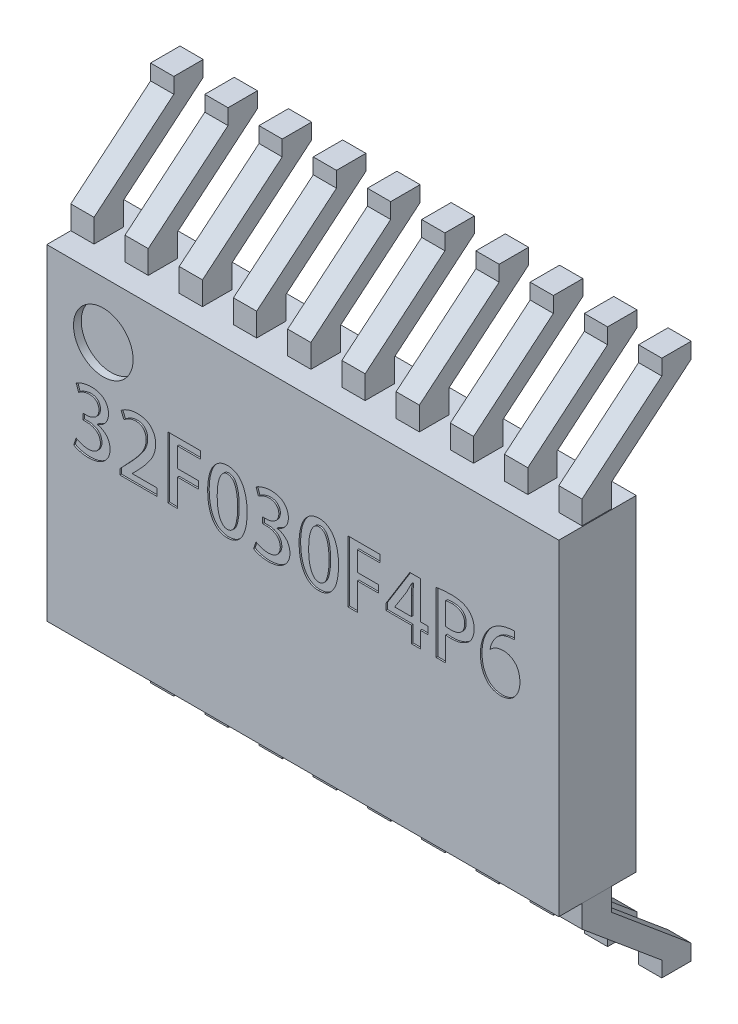
from build123d import *

# Parameters (mm, degrees)
ESQUISSE1_W                = 6.61
ESQUISSE1_H                = 4.21
CORPS_DEPTH                = 1
ESQUISSE2_R                = 0.385
ENL_V_MAT_EXTRU_1_DEPTH    = 0.1
TEXTE_DEPTH                = 0.02
BOSS_EXTRU_3_DEPTH         = 0.3
R_P_TITION_LIN_AIRE2_COUNT = 10
R_P_TITION_LIN_AIRE2_PITCH = 0.7
SYM_TRIE1_COPY_1_DEPTH     = 0.3
SYM_TRIE1_COPY_2_DEPTH     = 0.3
SYM_TRIE1_COPY_3_DEPTH     = 0.3
SYM_TRIE1_COPY_4_DEPTH     = 0.3
SYM_TRIE1_COPY_5_DEPTH     = 0.3
SYM_TRIE1_COPY_6_DEPTH     = 0.3
SYM_TRIE1_COPY_7_DEPTH     = 0.3
SYM_TRIE1_COPY_8_DEPTH     = 0.3
SYM_TRIE1_COPY_9_DEPTH     = 0.3


with BuildPart() as part:
    # Esquisse1 → Corps (new body)
    with BuildSketch(Plane.XY):
        Rectangle(ESQUISSE1_W, ESQUISSE1_H)
    extrude(amount=CORPS_DEPTH)

    # Esquisse2 → Enlèv. mat.-Extru.1 (cut)
    with BuildSketch(Plane.XY.offset(1)):
        with Locations((-2.575, 1.375)):
            Circle(ESQUISSE2_R)
    extrude(amount=-ENL_V_MAT_EXTRU_1_DEPTH, mode=Mode.SUBTRACT)

    # Esquisse3 → Texte (cut)
    with BuildSketch(Plane.XY.offset(1)):
        with BuildLine():
            add(Edge.make_bspline(
                [(-2.65303754, 0.421072717), (-2.647275821, 0.423050885), (-2.635918271, 0.426950267), (-2.619618319, 0.433860521), (-2.604408314, 0.44175305), (-2.590341582, 0.450549268), (-2.577253928, 0.460085935), (-2.565245508, 0.470492798), (-2.554535954, 0.481973881), (-2.544626724, 0.493988351), (-2.536120974, 0.506831635), (-2.528593683, 0.520098203), (-2.522293079, 0.533876611), (-2.516923774, 0.548027332), (-2.513018844, 0.56273688), (-2.510176776, 0.577844682), (-2.508265443, 0.593451553), (-2.508046918, 0.604025715), (-2.507936417, 0.60937275)],
                knots=[0, 0, 0, 0, 1.142850461, 2.252796655, 3.318527559, 4.354869455, 5.362872949, 6.354647905, 7.33116108, 8.305795594, 9.273479687, 10.217594684, 11.165254112, 12.113667972, 13.054082589, 14.016532539, 14.997020217, 16, 16, 16, 16], degree=3))
            add(Edge.make_bspline(
                [(-2.507936417, 0.60937275), (-2.508050098, 0.6160334), (-2.508273196, 0.629104953), (-2.510966223, 0.648283449), (-2.515190663, 0.666652481), (-2.521002821, 0.684247385), (-2.528861931, 0.700852669), (-2.538280244, 0.716644326), (-2.549339422, 0.731703408), (-2.562216712, 0.745727288), (-2.576706475, 0.758706), (-2.593170916, 0.7698765), (-2.611273029, 0.779450581), (-2.631121731, 0.787274025), (-2.652642483, 0.793700889), (-2.676013743, 0.798040932), (-2.70105348, 0.801187733), (-2.718357015, 0.801800391), (-2.72728642, 0.80211655)],
                knots=[0, 0, 0, 0, 0.970193423, 1.904008561, 2.816199263, 3.715045635, 4.598913464, 5.488196567, 6.391622429, 7.316994192, 8.258747533, 9.220312128, 10.209256713, 11.237617249, 12.325225682, 13.477568758, 14.698311634, 16, 16, 16, 16], degree=3))
            add(Edge.make_bspline(
                [(-2.72728642, 0.80211655), (-2.737423176, 0.801803048), (-2.757396521, 0.801185327), (-2.786723284, 0.797867905), (-2.81479364, 0.792372331), (-2.841342747, 0.78517277), (-2.865919415, 0.776659421), (-2.888035312, 0.767221444), (-2.907791824, 0.757508404), (-2.919350837, 0.749637385), (-2.924867711, 0.745880712)],
                knots=[0, 0, 0, 0, 1.168281151, 2.301967287, 3.396324189, 4.461200567, 5.469347965, 6.390373579, 7.23175906, 8, 8, 8, 8], degree=3))
            Line((-2.924867711, 0.745880712), (-2.894431877, 0.657171766))
            add(Edge.make_bspline(
                [(-2.894431877, 0.657171766), (-2.890312527, 0.660154959), (-2.881689893, 0.666399387), (-2.867258144, 0.674720571), (-2.851206862, 0.68288386), (-2.833694595, 0.690663427), (-2.815089464, 0.697746024), (-2.795384377, 0.702600431), (-2.775176939, 0.706116111), (-2.761415737, 0.706723996), (-2.754497309, 0.707029609)],
                knots=[0, 0, 0, 0, 0.808951706, 1.693300174, 2.647298677, 3.674056458, 4.742195602, 5.810003555, 6.898981895, 8, 8, 8, 8], degree=3))
            add(Edge.make_bspline(
                [(-2.754497309, 0.707029609), (-2.749452824, 0.706857939), (-2.739634004, 0.706523793), (-2.725418592, 0.704707528), (-2.712224678, 0.70183808), (-2.700075733, 0.698065024), (-2.688849206, 0.693405675), (-2.678744418, 0.687475999), (-2.669583869, 0.680608445), (-2.661400661, 0.672911816), (-2.654296993, 0.664368296), (-2.648064817, 0.655260776), (-2.642755497, 0.645605387), (-2.63853815, 0.635391552), (-2.63515538, 0.624677873), (-2.632755768, 0.613393758), (-2.6314001, 0.601545302), (-2.631228462, 0.593503137), (-2.631141277, 0.589418098)],
                knots=[0, 0, 0, 0, 1.256626411, 2.445955828, 3.563592353, 4.615523118, 5.610904047, 6.583878032, 7.525171958, 8.457385665, 9.374952795, 10.287009995, 11.202514788, 12.113880905, 13.034789483, 13.997264759, 14.982705545, 16, 16, 16, 16], degree=3))
            add(Edge.make_bspline(
                [(-2.631141277, 0.589418098), (-2.631527439, 0.583861326), (-2.632280429, 0.57302598), (-2.635355326, 0.557361818), (-2.639862522, 0.542808069), (-2.645819528, 0.529376866), (-2.653052856, 0.517001959), (-2.661961305, 0.50586206), (-2.672305611, 0.495843616), (-2.687776877, 0.484171207), (-2.708393418, 0.472154822), (-2.734338588, 0.461776114), (-2.760850793, 0.454980846), (-2.778896557, 0.454305511), (-2.787906234, 0.453968338)],
                knots=[0, 0, 0, 0, 0.870129898, 1.696696992, 2.489031529, 3.247306791, 3.989032865, 4.723528156, 5.470049698, 6.234235541, 7.748841047, 9.18391766, 10.59401934, 12, 12, 12, 12], degree=3))
            Line((-2.787906234, 0.453968338), (-2.839051398, 0.454119362))
            Line((-2.839051398, 0.454119362), (-2.839051398, 0.377928871))
            Line((-2.839051398, 0.377928871), (-2.785760749, 0.377928871))
            add(Edge.make_bspline(
                [(-2.785760749, 0.377928871), (-2.78017334, 0.377801343), (-2.769115482, 0.377548954), (-2.752746131, 0.375881796), (-2.736931418, 0.3730261), (-2.721688187, 0.369034089), (-2.706907991, 0.364112105), (-2.692756875, 0.357697772), (-2.679103028, 0.350283677), (-2.666097069, 0.341837341), (-2.653911145, 0.332347915), (-2.643516442, 0.321107807), (-2.634261145, 0.30895681), (-2.626698198, 0.295421209), (-2.620796377, 0.280611452), (-2.616475375, 0.264572043), (-2.61334401, 0.247379562), (-2.612716934, 0.235438645), (-2.612395998, 0.229327329)],
                knots=[0, 0, 0, 0, 1.046331669, 2.070760762, 3.07769869, 4.052736355, 5.019611495, 5.991172427, 6.958185709, 7.926625299, 8.893408334, 9.841308705, 10.784972102, 11.748294832, 12.73486321, 13.762806798, 14.855013103, 16, 16, 16, 16], degree=3))
            add(Edge.make_bspline(
                [(-2.612395998, 0.229327329), (-2.61245387, 0.224785863), (-2.612568099, 0.215821819), (-2.614355069, 0.202634781), (-2.616969009, 0.189777472), (-2.621200711, 0.177400279), (-2.626224107, 0.165198325), (-2.632889587, 0.153582483), (-2.640405805, 0.142182868), (-2.64917872, 0.131275389), (-2.659213388, 0.12110422), (-2.670893297, 0.112253473), (-2.683976122, 0.104726082), (-2.698440286, 0.09830045), (-2.71440129, 0.093407333), (-2.731696895, 0.089663847), (-2.750391581, 0.087020701), (-2.763356884, 0.086458713), (-2.770067985, 0.086167816)],
                knots=[0, 0, 0, 0, 0.908689764, 1.79359172, 2.660474082, 3.53163332, 4.408791585, 5.298742298, 6.208328095, 7.141290712, 8.09743137, 9.062159814, 10.065993647, 11.114141579, 12.224787869, 13.40249277, 14.655478157, 16, 16, 16, 16], degree=3))
            add(Edge.make_bspline(
                [(-2.770067985, 0.086167816), (-2.778190258, 0.086497618), (-2.794184648, 0.087147063), (-2.817634238, 0.090230312), (-2.840139239, 0.094879381), (-2.861343309, 0.101234325), (-2.88079062, 0.108425871), (-2.898127683, 0.115654753), (-2.913054531, 0.122880885), (-2.921737921, 0.128468266), (-2.925774741, 0.131065784)],
                knots=[0, 0, 0, 0, 1.18917369, 2.341722166, 3.456857348, 4.54890459, 5.577794999, 6.489989879, 7.298011528, 8, 8, 8, 8], degree=3))
            Line((-2.925774741, 0.131065784), (-2.957107714, 0.039212645))
            add(Edge.make_bspline(
                [(-2.957107714, 0.039212645), (-2.951914601, 0.036006482), (-2.940903181, 0.029208168), (-2.922164428, 0.020848348), (-2.900877489, 0.012789023), (-2.877114299, 0.005497882), (-2.851239411, -0.000715319), (-2.823699124, -0.005164408), (-2.794769943, -0.008100067), (-2.775013426, -0.008642318), (-2.76492815, -0.008919125)],
                knots=[0, 0, 0, 0, 0.729997043, 1.54787772, 2.451011449, 3.454793802, 4.521561951, 5.634403953, 6.792414255, 8, 8, 8, 8], degree=3))
            add(Edge.make_bspline(
                [(-2.76492815, -0.008919125), (-2.754033791, -0.008516165), (-2.732842786, -0.007732353), (-2.70211637, -0.004085595), (-2.673360764, 0.001505652), (-2.646524533, 0.008921647), (-2.621786851, 0.018715592), (-2.598880443, 0.030147163), (-2.578066057, 0.043843961), (-2.559328015, 0.059434326), (-2.542712973, 0.076507737), (-2.528243757, 0.094758421), (-2.51597377, 0.114027834), (-2.505721006, 0.134236597), (-2.497816282, 0.155540837), (-2.492292463, 0.177910772), (-2.488673885, 0.201243982), (-2.488214648, 0.217169643), (-2.487981765, 0.225245695)],
                knots=[0, 0, 0, 0, 1.285115458, 2.499723545, 3.644061708, 4.736936843, 5.777449697, 6.776609495, 7.750593257, 8.70842081, 9.645454328, 10.554876974, 11.449918558, 12.334804212, 13.22219996, 14.122903931, 15.048106989, 16, 16, 16, 16], degree=3))
            add(Edge.make_bspline(
                [(-2.487981765, 0.225245695), (-2.488280941, 0.232056418), (-2.488863577, 0.245320092), (-2.491459928, 0.264693486), (-2.495500259, 0.282957112), (-2.501015549, 0.300186771), (-2.507704528, 0.31643137), (-2.516198673, 0.331471242), (-2.525770767, 0.345652747), (-2.537095538, 0.35837474), (-2.549129222, 0.370196809), (-2.562008576, 0.380778142), (-2.575570287, 0.390201664), (-2.589712797, 0.398571819), (-2.604666649, 0.405459071), (-2.620104943, 0.411490205), (-2.636345215, 0.415961972), (-2.64745237, 0.418112775), (-2.65306116, 0.419198868)],
                knots=[0, 0, 0, 0, 1.174677739, 2.287648832, 3.36451242, 4.394646196, 5.402905017, 6.386620204, 7.367224245, 8.346134136, 9.316645531, 10.27310073, 11.215250019, 12.161235371, 13.101581117, 14.050115226, 15.015364879, 16, 16, 16, 16], degree=3))
            Line((-2.65306116, 0.419198868), (-2.65303754, 0.421072717))
        make_face()
        with BuildLine():
            Line((-1.881845179, 0.095918533), (-2.199995571, 0.095918533))
            Line((-2.199995571, 0.095918533), (-2.199995571, 0.098044383))
            Line((-2.199995571, 0.098044383), (-2.135210861, 0.165008681))
            add(Edge.make_bspline(
                [(-2.135210861, 0.165008681), (-2.126684854, 0.173560455), (-2.109828384, 0.190467868), (-2.085541592, 0.216174046), (-2.062372605, 0.241655001), (-2.040606682, 0.267155096), (-2.019925054, 0.292300467), (-2.000431951, 0.31725775), (-1.982592735, 0.342295752), (-1.965440015, 0.366820963), (-1.950155727, 0.391598499), (-1.936718755, 0.416643073), (-1.925401007, 0.442071917), (-1.915922962, 0.46779631), (-1.908719937, 0.493968121), (-1.903201901, 0.520356076), (-1.899848658, 0.5471602), (-1.899094125, 0.565121191), (-1.898714838, 0.574149766)],
                knots=[0, 0, 0, 0, 1.195381854, 2.363347745, 3.50053777, 4.604304725, 5.681810837, 6.723515834, 7.73832273, 8.724868519, 9.685653219, 10.618474166, 11.536235179, 12.438891752, 13.329671478, 14.220912006, 15.105693524, 16, 16, 16, 16], degree=3))
            add(Edge.make_bspline(
                [(-1.898714838, 0.574149766), (-1.898826668, 0.581817804), (-1.89904658, 0.596896949), (-1.901779188, 0.619075129), (-1.905847198, 0.640481007), (-1.912184655, 0.660916831), (-1.919968726, 0.680591696), (-1.929911817, 0.699190958), (-1.941487737, 0.716995459), (-1.954665059, 0.733955075), (-1.969942663, 0.749448663), (-1.987337862, 0.76298074), (-2.006726983, 0.774559007), (-2.028169196, 0.784060094), (-2.051608859, 0.791549565), (-2.076977441, 0.797342012), (-2.104414158, 0.80092342), (-2.123395844, 0.801710675), (-2.133182002, 0.80211655)],
                knots=[0, 0, 0, 0, 0.995320378, 1.957290544, 2.898101081, 3.821472585, 4.731739661, 5.642218458, 6.555304432, 7.487493673, 8.426937414, 9.373466941, 10.342092883, 11.352807763, 12.412470548, 13.533359811, 14.728304285, 16, 16, 16, 16], degree=3))
            add(Edge.make_bspline(
                [(-2.133182002, 0.80211655), (-2.144027841, 0.801731616), (-2.165234311, 0.800978967), (-2.196348965, 0.796999121), (-2.225970204, 0.790593019), (-2.25386974, 0.781532895), (-2.279981234, 0.771093308), (-2.303875857, 0.759017924), (-2.325850618, 0.746265313), (-2.338919693, 0.736242687), (-2.345275767, 0.731368238)],
                knots=[0, 0, 0, 0, 1.143909725, 2.236644427, 3.302870934, 4.334659843, 5.326304614, 6.264941716, 7.156163776, 8, 8, 8, 8], degree=3))
            Line((-2.345275767, 0.731368238), (-2.308666699, 0.644388022))
            add(Edge.make_bspline(
                [(-2.308666699, 0.644388022), (-2.303891728, 0.648257752), (-2.29409822, 0.656194604), (-2.278026631, 0.666985661), (-2.260558722, 0.677226656), (-2.242004046, 0.687108678), (-2.2222353, 0.695636159), (-2.201337391, 0.701831122), (-2.179590791, 0.70588252), (-2.164743975, 0.70664375), (-2.157218287, 0.707029609)],
                knots=[0, 0, 0, 0, 0.882843515, 1.810720216, 2.778130362, 3.791908233, 4.830190049, 5.865690636, 6.91814204, 8, 8, 8, 8], degree=3))
            add(Edge.make_bspline(
                [(-2.157218287, 0.707029609), (-2.151312252, 0.706791062), (-2.139854977, 0.706328299), (-2.123396723, 0.703785761), (-2.1081559, 0.700455018), (-2.094242445, 0.695587381), (-2.081707763, 0.689359127), (-2.070315058, 0.682111273), (-2.060412407, 0.673411231), (-2.051966623, 0.663452373), (-2.04457443, 0.652731493), (-2.038238086, 0.641303558), (-2.032731733, 0.629425739), (-2.028536007, 0.616871962), (-2.025217379, 0.603835414), (-2.02272212, 0.590210232), (-2.021592341, 0.575984044), (-2.021508627, 0.566340614), (-2.021466184, 0.561451351)],
                knots=[0, 0, 0, 0, 1.252980104, 2.430689377, 3.52761197, 4.558806516, 5.548436465, 6.491350754, 7.41553586, 8.332707944, 9.254912475, 10.173827287, 11.1018993, 12.028184129, 12.97713893, 13.954334826, 14.962838355, 16, 16, 16, 16], degree=3))
            add(Edge.make_bspline(
                [(-2.021466184, 0.561451351), (-2.021730986, 0.554082576), (-2.022264709, 0.539230458), (-2.02563517, 0.51689398), (-2.030636304, 0.494324971), (-2.038306167, 0.471678452), (-2.047586841, 0.448755028), (-2.059065119, 0.425649628), (-2.072523528, 0.40235924), (-2.088260827, 0.378867036), (-2.106026313, 0.354854995), (-2.125093801, 0.329520328), (-2.146386473, 0.303445746), (-2.169339233, 0.276161393), (-2.194339468, 0.24802299), (-2.22088206, 0.218589228), (-2.249570762, 0.188402962), (-2.269369762, 0.167984582), (-2.279516118, 0.157520815)],
                knots=[0, 0, 0, 0, 0.72150536, 1.454228671, 2.20835524, 2.982319522, 3.792345563, 4.628710786, 5.506385041, 6.424690228, 7.395867932, 8.431131342, 9.529291015, 10.691804108, 11.922384402, 13.214899875, 14.57272513, 16, 16, 16, 16], degree=3))
            Line((-2.279516118, 0.157520815), (-2.361957348, 0.071152519))
            Line((-2.361957348, 0.071152519), (-2.361957348, 0.000831296))
            Line((-2.361957348, 0.000831296), (-1.881845179, 0.000831296))
            Line((-1.881845179, 0.000831296), (-1.881845179, 0.095918533))
        make_face()
        Polygon((-1.617989163, -0.001960802), (-1.617989163, 0.349130533), (-1.344221515, 0.349130533), (-1.344221515, 0.444217769), (-1.617989163, 0.444217769), (-1.617989163, 0.697429769), (-1.323323221, 0.697429769), (-1.323323221, 0.792517005), (-1.740740656, 0.792517005), (-1.740740656, -0.001960802), align=None)
        with BuildLine():
            add(Edge.make_bspline(
                [(-0.976211214, -0.008843687), (-0.966331378, -0.008506859), (-0.946977895, -0.007847053), (-0.91878903, -0.002751415), (-0.892316707, 0.005568203), (-0.867515456, 0.01715383), (-0.844549105, 0.032150143), (-0.823197255, 0.050315123), (-0.80366065, 0.071791763), (-0.785944683, 0.096482413), (-0.770065632, 0.124226851), (-0.756345017, 0.155095827), (-0.744734125, 0.188950331), (-0.735321781, 0.225827553), (-0.727753523, 0.265708008), (-0.722448941, 0.308628078), (-0.71906861, 0.35454444), (-0.718605573, 0.386136466), (-0.718366926, 0.40241882)],
                knots=[0, 0, 0, 0, 0.870696281, 1.705595656, 2.516350062, 3.311357778, 4.111130694, 4.927465531, 5.776524699, 6.664348225, 7.60171378, 8.590083443, 9.638235951, 10.753539253, 11.94293492, 13.214798286, 14.564522568, 16, 16, 16, 16], degree=3))
            add(Edge.make_bspline(
                [(-0.718366926, 0.40241882), (-0.718502532, 0.417239614), (-0.718766668, 0.446107924), (-0.721924886, 0.488179879), (-0.726682956, 0.52795269), (-0.733326866, 0.565416959), (-0.742379845, 0.600515286), (-0.75296792, 0.633375065), (-0.76567825, 0.663884481), (-0.78029693, 0.69191911), (-0.796778778, 0.71728717), (-0.815530406, 0.739366571), (-0.836026153, 0.758377788), (-0.858630788, 0.773949358), (-0.883216972, 0.786174537), (-0.909805868, 0.794879079), (-0.938233972, 0.800641394), (-0.957895343, 0.801617378), (-0.96795125, 0.80211655)],
                knots=[0, 0, 0, 0, 1.348598241, 2.626833012, 3.837323855, 4.993252023, 6.086653137, 7.133754439, 8.132822275, 9.090804279, 10.007900934, 10.879914043, 11.720575117, 12.54490278, 13.369396272, 14.210545074, 15.084774353, 16, 16, 16, 16], degree=3))
            add(Edge.make_bspline(
                [(-0.96795125, 0.80211655), (-0.977951472, 0.801702133), (-0.997480983, 0.800892814), (-1.025884474, 0.795640613), (-1.052547426, 0.787203348), (-1.07746464, 0.775270327), (-1.100582806, 0.759984873), (-1.122079997, 0.741513763), (-1.1417708, 0.719741048), (-1.159592382, 0.694774004), (-1.175636403, 0.666897071), (-1.189481067, 0.636073236), (-1.201274051, 0.602489239), (-1.210882002, 0.56613175), (-1.218330598, 0.527019485), (-1.223964034, 0.485193844), (-1.227205802, 0.440513793), (-1.227807636, 0.409780923), (-1.228117587, 0.39395321)],
                knots=[0, 0, 0, 0, 0.885786215, 1.729858878, 2.550092024, 3.356753299, 4.168966232, 4.998392219, 5.861110803, 6.763026954, 7.71096382, 8.705887709, 9.752087664, 10.860900304, 12.034055661, 13.277157086, 14.597710659, 16, 16, 16, 16], degree=3))
            add(Edge.make_bspline(
                [(-1.228117587, 0.39395321), (-1.227934984, 0.378980195), (-1.227579183, 0.349805233), (-1.224223558, 0.307238109), (-1.219459671, 0.267026518), (-1.212294401, 0.229220718), (-1.203295372, 0.193796131), (-1.192296775, 0.160648506), (-1.179148808, 0.129979427), (-1.164238345, 0.10170925), (-1.147412192, 0.076266169), (-1.128586814, 0.05392706), (-1.107739273, 0.035004747), (-1.084973662, 0.019459778), (-1.060479123, 0.007014257), (-1.034001443, -0.001650348), (-1.005787155, -0.007461458), (-0.986272543, -0.008425021), (-0.976211214, -0.008843687)],
                knots=[0, 0, 0, 0, 1.353423849, 2.637150346, 3.858261108, 5.012665895, 6.113189956, 7.160539399, 8.16670341, 9.126620219, 10.046469106, 10.919123896, 11.760946034, 12.583565319, 13.404631502, 14.235884548, 15.095383165, 16, 16, 16, 16], degree=3))
        make_face()
        with BuildLine():
            add(Edge.make_bspline(
                [(-0.974130537, 0.08624355), (-0.979257046, 0.086520157), (-0.989368394, 0.087065728), (-1.003931591, 0.091402067), (-1.01763201, 0.097940455), (-1.030260583, 0.107227393), (-1.042021882, 0.118886252), (-1.052759504, 0.133133674), (-1.062528897, 0.149870342), (-1.071380439, 0.168985269), (-1.079346122, 0.190312781), (-1.086309795, 0.213790683), (-1.091915013, 0.239437353), (-1.096781979, 0.267117034), (-1.100504264, 0.296936661), (-1.103175747, 0.328809329), (-1.10486481, 0.362793815), (-1.105095862, 0.386140626), (-1.10521507, 0.398186015)],
                knots=[0, 0, 0, 0, 0.666398031, 1.31438028, 1.962893771, 2.634846584, 3.344681637, 4.112349672, 4.950647476, 5.86347927, 6.851779693, 7.912578033, 9.049075701, 10.267961701, 11.570849897, 12.960254545, 14.431695278, 16, 16, 16, 16], degree=3))
            add(Edge.make_bspline(
                [(-1.10521507, 0.398186015), (-1.105064908, 0.410232957), (-1.104773177, 0.433637594), (-1.102673084, 0.467608971), (-1.09997165, 0.499455058), (-1.095833822, 0.529102675), (-1.090850517, 0.556649195), (-1.084401024, 0.581940848), (-1.077296285, 0.605208368), (-1.068807432, 0.626200962), (-1.059546259, 0.644962067), (-1.049396979, 0.661295867), (-1.038498575, 0.675195651), (-1.02685275, 0.686715576), (-1.01428424, 0.695654636), (-1.00095621, 0.702085714), (-0.986841336, 0.706248304), (-0.977100319, 0.706767548), (-0.972184055, 0.707029609)],
                knots=[0, 0, 0, 0, 1.581052361, 3.071646956, 4.466225399, 5.774778899, 6.999321057, 8.13822646, 9.198772947, 10.189899711, 11.106816715, 11.941785511, 12.709246862, 13.420164871, 14.084452052, 14.723397775, 15.355702508, 16, 16, 16, 16], degree=3))
            add(Edge.make_bspline(
                [(-0.972184055, 0.707029609), (-0.966661828, 0.706671539), (-0.955807926, 0.705967755), (-0.940231819, 0.701554431), (-0.925753, 0.694878891), (-0.912575214, 0.685408412), (-0.900585164, 0.673489384), (-0.889801914, 0.659026749), (-0.880108403, 0.64213132), (-0.871821061, 0.622727527), (-0.864431751, 0.601244144), (-0.858192666, 0.577773871), (-0.852710338, 0.552463251), (-0.848386484, 0.525256705), (-0.845125897, 0.496145175), (-0.842694813, 0.465190404), (-0.841371359, 0.432312186), (-0.841204233, 0.409776962), (-0.841118271, 0.398186015)],
                knots=[0, 0, 0, 0, 0.720966059, 1.417054204, 2.100078545, 2.793954457, 3.524557493, 4.299796832, 5.143005199, 6.062454772, 7.05102079, 8.107851098, 9.232113941, 10.431958672, 11.703767055, 13.056962832, 14.486254779, 16, 16, 16, 16], degree=3))
            add(Edge.make_bspline(
                [(-0.841118271, 0.398186015), (-0.841106323, 0.387804968), (-0.841082825, 0.367389544), (-0.842115154, 0.337283216), (-0.844253007, 0.308345867), (-0.847213182, 0.28054568), (-0.851333206, 0.253927999), (-0.856283786, 0.228400845), (-0.86214337, 0.204008426), (-0.869000281, 0.180992511), (-0.876871395, 0.159791726), (-0.886479244, 0.141127495), (-0.897324361, 0.125024255), (-0.909828854, 0.111619582), (-0.923929717, 0.101126947), (-0.939255107, 0.093008114), (-0.956225876, 0.087971479), (-0.968070737, 0.086779511), (-0.974130537, 0.08624355)],
                knots=[0, 0, 0, 0, 1.341939408, 2.639065411, 3.893110861, 5.09230624, 6.252216656, 7.373906837, 8.453023627, 9.493766498, 10.477323239, 11.371762395, 12.201113983, 12.97990739, 13.729039495, 14.463267275, 15.211379073, 16, 16, 16, 16], degree=3))
        make_face(mode=Mode.SUBTRACT)
        with BuildLine():
            add(Edge.make_bspline(
                [(-0.331041647, 0.421072717), (-0.325279928, 0.423050885), (-0.313922377, 0.426950267), (-0.297622425, 0.433860521), (-0.28241242, 0.44175305), (-0.268345689, 0.450549268), (-0.255258035, 0.460085935), (-0.243249615, 0.470492798), (-0.232540061, 0.481973881), (-0.222630831, 0.493988351), (-0.21412508, 0.506831635), (-0.206597789, 0.520098203), (-0.200297185, 0.533876611), (-0.194927881, 0.548027332), (-0.191022951, 0.56273688), (-0.188180883, 0.577844682), (-0.186269549, 0.593451553), (-0.186051025, 0.604025715), (-0.185940524, 0.60937275)],
                knots=[0, 0, 0, 0, 1.142850461, 2.252796655, 3.318527559, 4.354869455, 5.362872949, 6.354647905, 7.33116108, 8.305795594, 9.273479687, 10.217594684, 11.165254112, 12.113667972, 13.054082589, 14.016532539, 14.997020217, 16, 16, 16, 16], degree=3))
            add(Edge.make_bspline(
                [(-0.185940524, 0.60937275), (-0.186054204, 0.6160334), (-0.186277303, 0.629104953), (-0.188970329, 0.648283449), (-0.19319477, 0.666652481), (-0.199006928, 0.684247385), (-0.206866038, 0.700852669), (-0.21628435, 0.716644326), (-0.227343528, 0.731703408), (-0.240220819, 0.745727288), (-0.254710582, 0.758706), (-0.271175022, 0.7698765), (-0.289277136, 0.779450581), (-0.309125838, 0.787274025), (-0.33064659, 0.793700889), (-0.35401785, 0.798040932), (-0.379057587, 0.801187733), (-0.396361122, 0.801800391), (-0.405290526, 0.80211655)],
                knots=[0, 0, 0, 0, 0.970193423, 1.904008561, 2.816199263, 3.715045635, 4.598913464, 5.488196567, 6.391622429, 7.316994192, 8.258747533, 9.220312128, 10.209256713, 11.237617249, 12.325225682, 13.477568758, 14.698311634, 16, 16, 16, 16], degree=3))
            add(Edge.make_bspline(
                [(-0.405290526, 0.80211655), (-0.415427283, 0.801803048), (-0.435400628, 0.801185327), (-0.46472739, 0.797867905), (-0.492797747, 0.792372331), (-0.519346853, 0.78517277), (-0.543923522, 0.776659421), (-0.566039419, 0.767221444), (-0.585795931, 0.757508404), (-0.597354943, 0.749637385), (-0.602871818, 0.745880712)],
                knots=[0, 0, 0, 0, 1.168281151, 2.301967287, 3.396324189, 4.461200567, 5.469347965, 6.390373579, 7.23175906, 8, 8, 8, 8], degree=3))
            Line((-0.602871818, 0.745880712), (-0.572435983, 0.657171766))
            add(Edge.make_bspline(
                [(-0.572435983, 0.657171766), (-0.568316634, 0.660154959), (-0.559694, 0.666399387), (-0.54526225, 0.674720571), (-0.529210968, 0.68288386), (-0.511698702, 0.690663427), (-0.49309357, 0.697746024), (-0.473388484, 0.702600431), (-0.453181045, 0.706116111), (-0.439419844, 0.706723996), (-0.432501416, 0.707029609)],
                knots=[0, 0, 0, 0, 0.808951706, 1.693300174, 2.647298677, 3.674056458, 4.742195602, 5.810003555, 6.898981895, 8, 8, 8, 8], degree=3))
            add(Edge.make_bspline(
                [(-0.432501416, 0.707029609), (-0.427456931, 0.706857939), (-0.417638111, 0.706523793), (-0.403422699, 0.704707528), (-0.390228785, 0.70183808), (-0.37807984, 0.698065024), (-0.366853313, 0.693405675), (-0.356748524, 0.687475999), (-0.347587976, 0.680608445), (-0.339404768, 0.672911816), (-0.3323011, 0.664368296), (-0.326068924, 0.655260776), (-0.320759603, 0.645605387), (-0.316542256, 0.635391552), (-0.313159487, 0.624677873), (-0.310759875, 0.613393758), (-0.309404207, 0.601545302), (-0.309232568, 0.593503137), (-0.309145384, 0.589418098)],
                knots=[0, 0, 0, 0, 1.256626411, 2.445955828, 3.563592353, 4.615523118, 5.610904047, 6.583878032, 7.525171958, 8.457385665, 9.374952795, 10.287009995, 11.202514788, 12.113880905, 13.034789483, 13.997264759, 14.982705545, 16, 16, 16, 16], degree=3))
            add(Edge.make_bspline(
                [(-0.309145384, 0.589418098), (-0.309531546, 0.583861326), (-0.310284535, 0.57302598), (-0.313359433, 0.557361818), (-0.317866629, 0.542808069), (-0.323823634, 0.529376866), (-0.331056962, 0.517001959), (-0.339965412, 0.50586206), (-0.350309718, 0.495843616), (-0.365780983, 0.484171207), (-0.386397525, 0.472154822), (-0.412342695, 0.461776114), (-0.438854899, 0.454980846), (-0.456900663, 0.454305511), (-0.465910341, 0.453968338)],
                knots=[0, 0, 0, 0, 0.870129898, 1.696696992, 2.489031529, 3.247306791, 3.989032865, 4.723528156, 5.470049698, 6.234235541, 7.748841047, 9.18391766, 10.59401934, 12, 12, 12, 12], degree=3))
            Line((-0.465910341, 0.453968338), (-0.517055505, 0.454119362))
            Line((-0.517055505, 0.454119362), (-0.517055505, 0.377928871))
            Line((-0.517055505, 0.377928871), (-0.463764856, 0.377928871))
            add(Edge.make_bspline(
                [(-0.463764856, 0.377928871), (-0.458177447, 0.377801343), (-0.447119589, 0.377548954), (-0.430750238, 0.375881796), (-0.414935524, 0.3730261), (-0.399692293, 0.369034089), (-0.384912097, 0.364112105), (-0.370760981, 0.357697772), (-0.357107135, 0.350283677), (-0.344101175, 0.341837341), (-0.331915252, 0.332347915), (-0.321520549, 0.321107807), (-0.312265252, 0.30895681), (-0.304702305, 0.295421209), (-0.298800484, 0.280611452), (-0.294479481, 0.264572043), (-0.291348117, 0.247379562), (-0.29072104, 0.235438645), (-0.290400105, 0.229327329)],
                knots=[0, 0, 0, 0, 1.046331669, 2.070760762, 3.07769869, 4.052736355, 5.019611495, 5.991172427, 6.958185709, 7.926625299, 8.893408334, 9.841308705, 10.784972102, 11.748294832, 12.73486321, 13.762806798, 14.855013103, 16, 16, 16, 16], degree=3))
            add(Edge.make_bspline(
                [(-0.290400105, 0.229327329), (-0.290457977, 0.224785863), (-0.290572205, 0.215821819), (-0.292359176, 0.202634781), (-0.294973116, 0.189777472), (-0.299204818, 0.177400279), (-0.304228214, 0.165198325), (-0.310893694, 0.153582483), (-0.318409912, 0.142182868), (-0.327182826, 0.131275389), (-0.337217495, 0.12110422), (-0.348897404, 0.112253473), (-0.361980228, 0.104726082), (-0.376444393, 0.09830045), (-0.392405396, 0.093407333), (-0.409701001, 0.089663847), (-0.428395687, 0.087020701), (-0.44136099, 0.086458713), (-0.448072091, 0.086167816)],
                knots=[0, 0, 0, 0, 0.908689764, 1.79359172, 2.660474082, 3.53163332, 4.408791585, 5.298742298, 6.208328095, 7.141290712, 8.09743137, 9.062159814, 10.065993647, 11.114141579, 12.224787869, 13.40249277, 14.655478157, 16, 16, 16, 16], degree=3))
            add(Edge.make_bspline(
                [(-0.448072091, 0.086167816), (-0.456194365, 0.086497618), (-0.472188755, 0.087147063), (-0.495638345, 0.090230312), (-0.518143346, 0.094879381), (-0.539347416, 0.101234325), (-0.558794727, 0.108425871), (-0.57613179, 0.115654753), (-0.591058638, 0.122880885), (-0.599742027, 0.128468266), (-0.603778847, 0.131065784)],
                knots=[0, 0, 0, 0, 1.18917369, 2.341722166, 3.456857348, 4.54890459, 5.577794999, 6.489989879, 7.298011528, 8, 8, 8, 8], degree=3))
            Line((-0.603778847, 0.131065784), (-0.63511182, 0.039212645))
            add(Edge.make_bspline(
                [(-0.63511182, 0.039212645), (-0.629918708, 0.036006482), (-0.618907288, 0.029208168), (-0.600168534, 0.020848348), (-0.578881596, 0.012789023), (-0.555118406, 0.005497882), (-0.529243517, -0.000715319), (-0.50170323, -0.005164408), (-0.472774049, -0.008100067), (-0.453017532, -0.008642318), (-0.442932257, -0.008919125)],
                knots=[0, 0, 0, 0, 0.729997043, 1.54787772, 2.451011449, 3.454793802, 4.521561951, 5.634403953, 6.792414255, 8, 8, 8, 8], degree=3))
            add(Edge.make_bspline(
                [(-0.442932257, -0.008919125), (-0.432037897, -0.008516165), (-0.410846893, -0.007732353), (-0.380120477, -0.004085595), (-0.35136487, 0.001505652), (-0.32452864, 0.008921647), (-0.299790958, 0.018715592), (-0.27688455, 0.030147163), (-0.256070164, 0.043843961), (-0.237332122, 0.059434326), (-0.220717079, 0.076507737), (-0.206247864, 0.094758421), (-0.193977877, 0.114027834), (-0.183725112, 0.134236597), (-0.175820389, 0.155540837), (-0.17029657, 0.177910772), (-0.166677991, 0.201243982), (-0.166218755, 0.217169643), (-0.165985872, 0.225245695)],
                knots=[0, 0, 0, 0, 1.285115458, 2.499723545, 3.644061708, 4.736936843, 5.777449697, 6.776609495, 7.750593257, 8.70842081, 9.645454328, 10.554876974, 11.449918558, 12.334804212, 13.22219996, 14.122903931, 15.048106989, 16, 16, 16, 16], degree=3))
            add(Edge.make_bspline(
                [(-0.165985872, 0.225245695), (-0.166285048, 0.232056418), (-0.166867684, 0.245320092), (-0.169464035, 0.264693486), (-0.173504366, 0.282957112), (-0.179019655, 0.300186771), (-0.185708635, 0.31643137), (-0.19420278, 0.331471242), (-0.203774873, 0.345652747), (-0.215099645, 0.35837474), (-0.227133328, 0.370196809), (-0.240012682, 0.380778142), (-0.253574394, 0.390201664), (-0.267716903, 0.398571819), (-0.282670755, 0.405459071), (-0.298109049, 0.411490205), (-0.314349322, 0.415961972), (-0.325456477, 0.418112775), (-0.331065267, 0.419198868)],
                knots=[0, 0, 0, 0, 1.174677739, 2.287648832, 3.36451242, 4.394646196, 5.402905017, 6.386620204, 7.367224245, 8.346134136, 9.316645531, 10.27310073, 11.215250019, 12.161235371, 13.101581117, 14.050115226, 15.015364879, 16, 16, 16, 16], degree=3))
            Line((-0.331065267, 0.419198868), (-0.331041647, 0.421072717))
        make_face()
        with BuildLine():
            add(Edge.make_bspline(
                [(0.204136699, -0.008843687), (0.214016535, -0.008506859), (0.233370018, -0.007847053), (0.261558882, -0.002751415), (0.288031206, 0.005568203), (0.312832456, 0.01715383), (0.335798807, 0.032150143), (0.357150657, 0.050315123), (0.376687263, 0.071791763), (0.394403229, 0.096482413), (0.41028228, 0.124226851), (0.424002896, 0.155095827), (0.435613788, 0.188950331), (0.445026132, 0.225827553), (0.452594389, 0.265708008), (0.457898972, 0.308628078), (0.461279302, 0.35454444), (0.46174234, 0.386136466), (0.461980987, 0.40241882)],
                knots=[0, 0, 0, 0, 0.870696281, 1.705595656, 2.516350062, 3.311357778, 4.111130694, 4.927465531, 5.776524699, 6.664348225, 7.60171378, 8.590083443, 9.638235951, 10.753539253, 11.94293492, 13.214798286, 14.564522568, 16, 16, 16, 16], degree=3))
            add(Edge.make_bspline(
                [(0.461980987, 0.40241882), (0.461845381, 0.417239614), (0.461581245, 0.446107924), (0.458423026, 0.488179879), (0.453664957, 0.52795269), (0.447021047, 0.565416959), (0.437968067, 0.600515286), (0.427379992, 0.633375065), (0.414669662, 0.663884481), (0.400050982, 0.69191911), (0.383569134, 0.71728717), (0.364817506, 0.739366571), (0.34432176, 0.758377788), (0.321717125, 0.773949358), (0.297130941, 0.786174537), (0.270542045, 0.794879079), (0.242113941, 0.800641394), (0.222452569, 0.801617378), (0.212396662, 0.80211655)],
                knots=[0, 0, 0, 0, 1.348598241, 2.626833012, 3.837323855, 4.993252023, 6.086653137, 7.133754439, 8.132822275, 9.090804279, 10.007900934, 10.879914043, 11.720575117, 12.54490278, 13.369396272, 14.210545074, 15.084774353, 16, 16, 16, 16], degree=3))
            add(Edge.make_bspline(
                [(0.212396662, 0.80211655), (0.202396441, 0.801702133), (0.182866929, 0.800892814), (0.154463438, 0.795640613), (0.127800487, 0.787203348), (0.102883273, 0.775270327), (0.079765106, 0.759984873), (0.058267915, 0.741513763), (0.038577112, 0.719741048), (0.02075553, 0.694774004), (0.004711509, 0.666897071), (-0.009133155, 0.636073236), (-0.020926139, 0.602489239), (-0.030534089, 0.56613175), (-0.037982685, 0.527019485), (-0.043616122, 0.485193844), (-0.046857889, 0.440513793), (-0.047459724, 0.409780923), (-0.047769674, 0.39395321)],
                knots=[0, 0, 0, 0, 0.885786215, 1.729858878, 2.550092024, 3.356753299, 4.168966232, 4.998392219, 5.861110803, 6.763026954, 7.71096382, 8.705887709, 9.752087664, 10.860900304, 12.034055661, 13.277157086, 14.597710659, 16, 16, 16, 16], degree=3))
            add(Edge.make_bspline(
                [(-0.047769674, 0.39395321), (-0.047587072, 0.378980195), (-0.04723127, 0.349805233), (-0.043875645, 0.307238109), (-0.039111758, 0.267026518), (-0.031946489, 0.229220718), (-0.022947459, 0.193796131), (-0.011948863, 0.160648506), (0.001199105, 0.129979427), (0.016109567, 0.10170925), (0.032935721, 0.076266169), (0.051761098, 0.05392706), (0.07260864, 0.035004747), (0.095374251, 0.019459778), (0.11986879, 0.007014257), (0.146346469, -0.001650348), (0.174560757, -0.007461458), (0.194075369, -0.008425021), (0.204136699, -0.008843687)],
                knots=[0, 0, 0, 0, 1.353423849, 2.637150346, 3.858261108, 5.012665895, 6.113189956, 7.160539399, 8.16670341, 9.126620219, 10.046469106, 10.919123896, 11.760946034, 12.583565319, 13.404631502, 14.235884548, 15.095383165, 16, 16, 16, 16], degree=3))
        make_face()
        with BuildLine():
            add(Edge.make_bspline(
                [(0.206217375, 0.08624355), (0.201090866, 0.086520157), (0.190979519, 0.087065728), (0.176416321, 0.091402067), (0.162715902, 0.097940455), (0.150087329, 0.107227393), (0.13832603, 0.118886252), (0.127588408, 0.133133674), (0.117819015, 0.149870342), (0.108967473, 0.168985269), (0.101001791, 0.190312781), (0.094038118, 0.213790683), (0.0884329, 0.239437353), (0.083565933, 0.267117034), (0.079843649, 0.296936661), (0.077172166, 0.328809329), (0.075483103, 0.362793815), (0.07525205, 0.386140626), (0.075132843, 0.398186015)],
                knots=[0, 0, 0, 0, 0.666398031, 1.31438028, 1.962893771, 2.634846584, 3.344681637, 4.112349672, 4.950647476, 5.86347927, 6.851779693, 7.912578033, 9.049075701, 10.267961701, 11.570849897, 12.960254545, 14.431695278, 16, 16, 16, 16], degree=3))
            add(Edge.make_bspline(
                [(0.075132843, 0.398186015), (0.075283004, 0.410232957), (0.075574736, 0.433637594), (0.077674829, 0.467608971), (0.080376262, 0.499455058), (0.084514091, 0.529102675), (0.089497396, 0.556649195), (0.095946888, 0.581940848), (0.103051628, 0.605208368), (0.11154048, 0.626200962), (0.120801654, 0.644962067), (0.130950933, 0.661295867), (0.141849338, 0.675195651), (0.153495163, 0.686715576), (0.166063673, 0.695654636), (0.179391703, 0.702085714), (0.193506577, 0.706248304), (0.203247594, 0.706767548), (0.208163857, 0.707029609)],
                knots=[0, 0, 0, 0, 1.581052361, 3.071646956, 4.466225399, 5.774778899, 6.999321057, 8.13822646, 9.198772947, 10.189899711, 11.106816715, 11.941785511, 12.709246862, 13.420164871, 14.084452052, 14.723397775, 15.355702508, 16, 16, 16, 16], degree=3))
            add(Edge.make_bspline(
                [(0.208163857, 0.707029609), (0.213686084, 0.706671539), (0.224539987, 0.705967755), (0.240116094, 0.701554431), (0.254594913, 0.694878891), (0.267772699, 0.685408412), (0.279762748, 0.673489384), (0.290545998, 0.659026749), (0.300239509, 0.64213132), (0.308526851, 0.622727527), (0.315916162, 0.601244144), (0.322155246, 0.577773871), (0.327637574, 0.552463251), (0.331961428, 0.525256705), (0.335222016, 0.496145175), (0.3376531, 0.465190404), (0.338976553, 0.432312186), (0.33914368, 0.409776962), (0.339229641, 0.398186015)],
                knots=[0, 0, 0, 0, 0.720966059, 1.417054204, 2.100078545, 2.793954457, 3.524557493, 4.299796832, 5.143005199, 6.062454772, 7.05102079, 8.107851098, 9.232113941, 10.431958672, 11.703767055, 13.056962832, 14.486254779, 16, 16, 16, 16], degree=3))
            add(Edge.make_bspline(
                [(0.339229641, 0.398186015), (0.339241589, 0.387804968), (0.339265087, 0.367389544), (0.338232758, 0.337283216), (0.336094905, 0.308345867), (0.33313473, 0.28054568), (0.329014707, 0.253927999), (0.324064126, 0.228400845), (0.318204543, 0.204008426), (0.311347631, 0.180992511), (0.303476517, 0.159791726), (0.293868668, 0.141127495), (0.283023552, 0.125024255), (0.270519059, 0.111619582), (0.256418196, 0.101126947), (0.241092806, 0.093008114), (0.224122037, 0.087971479), (0.212277176, 0.086779511), (0.206217375, 0.08624355)],
                knots=[0, 0, 0, 0, 1.341939408, 2.639065411, 3.893110861, 5.09230624, 6.252216656, 7.373906837, 8.453023627, 9.493766498, 10.477323239, 11.371762395, 12.201113983, 12.97990739, 13.729039495, 14.463267275, 15.211379073, 16, 16, 16, 16], degree=3))
        make_face(mode=Mode.SUBTRACT)
        Polygon((0.70400673, -0.001960802), (0.70400673, 0.349130533), (0.977774378, 0.349130533), (0.977774378, 0.444217769), (0.70400673, 0.444217769), (0.70400673, 0.697429769), (0.998672672, 0.697429769), (0.998672672, 0.792517005), (0.581255237, 0.792517005), (0.581255237, -0.001960802), align=None)
        Polygon((1.517114815, 0.204005937), (1.615336795, 0.204005937), (1.615336795, 0.299093026), (1.517114815, 0.299093026), (1.517114815, 0.782571272), (1.38232082, 0.782571272), (1.074070988, 0.285042924), (1.074070988, 0.204005937), (1.403219114, 0.204005937), (1.403219114, -0.003932086), (1.517114815, -0.003932086), align=None)
        with BuildLine():
            Line((1.187966688, 0.301163663), (1.338434403, 0.539286995))
            add(Edge.make_bspline(
                [(1.338434403, 0.539286995), (1.343791085, 0.549495818), (1.354530313, 0.569962759), (1.370864197, 0.601186932), (1.387346666, 0.63414365), (1.398455941, 0.656832221), (1.404233617, 0.668632021)],
                knots=[0, 0, 0, 0, 0.953276043, 1.911155014, 2.913640166, 4, 4, 4, 4], degree=3))
            Line((1.404233617, 0.668632021), (1.408443687, 0.668675571))
            add(Edge.make_bspline(
                [(1.408443687, 0.668675571), (1.407004569, 0.646042957), (1.404132291, 0.600871443), (1.403493933, 0.555613243), (1.403175416, 0.533031089)],
                knots=[0, 0, 0, 0, 1.0020746, 2, 2, 2, 2], degree=3))
            Line((1.403175416, 0.533031089), (1.403219114, 0.299093026))
            Line((1.403219114, 0.299093026), (1.187966688, 0.299093026))
            Line((1.187966688, 0.299093026), (1.187966688, 0.301163663))
        make_face(mode=Mode.SUBTRACT)
        with BuildLine():
            Line((1.722903218, 0.002180769), (1.845654711, 0.002180769))
            Line((1.845654711, 0.002180769), (1.845654711, 0.315598337))
            add(Edge.make_bspline(
                [(1.845654711, 0.315598337), (1.850784816, 0.314688306), (1.861352687, 0.312813665), (1.877827279, 0.31128616), (1.895277308, 0.310329177), (1.907230453, 0.310346433), (1.913379592, 0.31035531)],
                knots=[0, 0, 0, 0, 0.918571729, 1.892231672, 2.915686383, 4, 4, 4, 4], degree=3))
            add(Edge.make_bspline(
                [(1.913379592, 0.31035531), (1.922707476, 0.310360405), (1.941145726, 0.310370476), (1.968420643, 0.312927442), (1.995009729, 0.317101156), (2.02090009, 0.323293444), (2.046079436, 0.331541754), (2.070602248, 0.341501109), (2.094415682, 0.353351441), (2.117377728, 0.366936264), (2.138813639, 0.382832593), (2.157777398, 0.401598975), (2.173842813, 0.423110537), (2.187272247, 0.447164272), (2.197965599, 0.473740754), (2.205951188, 0.502902729), (2.211272195, 0.534616757), (2.212512111, 0.556693711), (2.213152889, 0.568102902)],
                knots=[0, 0, 0, 0, 1.002223409, 1.981075816, 2.941057117, 3.893567037, 4.839120738, 5.786658294, 6.736252809, 7.695867274, 8.651375827, 9.597441389, 10.552949943, 11.527852714, 12.550822771, 13.624507394, 14.772364707, 16, 16, 16, 16], degree=3))
            add(Edge.make_bspline(
                [(2.213152889, 0.568102902), (2.21275988, 0.577035485), (2.211992654, 0.594473489), (2.208168609, 0.619785613), (2.202284023, 0.643538299), (2.194299388, 0.665792778), (2.18395464, 0.686388329), (2.171616016, 0.705506512), (2.157107478, 0.723051951), (2.145813541, 0.733214333), (2.140137003, 0.738322132)],
                knots=[0, 0, 0, 0, 1.121960372, 2.190267843, 3.207584746, 4.190239261, 5.152208329, 6.094546313, 7.042284316, 8, 8, 8, 8], degree=3))
            add(Edge.make_bspline(
                [(2.140137003, 0.738322132), (2.133752977, 0.743473546), (2.120784072, 0.753938447), (2.098703273, 0.766887052), (2.074454816, 0.777871245), (2.047951925, 0.787000681), (2.019091272, 0.793912096), (1.987925169, 0.798542519), (1.954513944, 0.801736222), (1.931477951, 0.801986999), (1.919577627, 0.80211655)],
                knots=[0, 0, 0, 0, 0.838628006, 1.70364077, 2.610636308, 3.559859354, 4.568055018, 5.643200099, 6.782484425, 8, 8, 8, 8], degree=3))
            add(Edge.make_bspline(
                [(1.919577627, 0.80211655), (1.909549449, 0.801936481), (1.889994146, 0.801585339), (1.861466962, 0.800715184), (1.834500862, 0.799376633), (1.809106609, 0.797519471), (1.785254687, 0.795482207), (1.762973445, 0.792907781), (1.742305022, 0.789921587), (1.729095468, 0.787538885), (1.722752194, 0.786394703)],
                knots=[0, 0, 0, 0, 1.217605855, 2.374374404, 3.464660226, 4.494999595, 5.465333604, 6.370582827, 7.217548217, 8, 8, 8, 8], degree=3))
            Line((1.722752194, 0.786394703), (1.722903218, 0.002180769))
        make_face()
        with BuildLine():
            add(Edge.make_bspline(
                [(1.845654711, 0.699887931), (1.85038151, 0.700819169), (1.861083755, 0.702927642), (1.879379692, 0.704864142), (1.901718233, 0.706345228), (1.918012525, 0.706789234), (1.926833865, 0.707029609)],
                knots=[0, 0, 0, 0, 0.7081459, 1.603358068, 2.702515415, 4, 4, 4, 4], degree=3))
            add(Edge.make_bspline(
                [(1.926833865, 0.707029609), (1.932833791, 0.706904303), (1.944554827, 0.706659513), (1.961694056, 0.70501942), (1.97790855, 0.702133111), (1.993224296, 0.698204586), (2.007650467, 0.693291841), (2.021087744, 0.686988067), (2.033617764, 0.679631723), (2.045154406, 0.671108448), (2.055701619, 0.661623868), (2.064778791, 0.650795538), (2.072594436, 0.638894932), (2.078918998, 0.62581509), (2.083920123, 0.61166656), (2.087530257, 0.596414351), (2.089816649, 0.580062346), (2.090203063, 0.568765614), (2.090401544, 0.562963067)],
                knots=[0, 0, 0, 0, 1.16517395, 2.276202082, 3.339667925, 4.360262278, 5.344409501, 6.294443781, 7.237649562, 8.161467064, 9.075802852, 9.985465996, 10.897442204, 11.83402534, 12.799705885, 13.806079676, 14.873096483, 16, 16, 16, 16], degree=3))
            add(Edge.make_bspline(
                [(2.090401544, 0.562963067), (2.090198681, 0.556809052), (2.089803207, 0.544812045), (2.087567676, 0.527385125), (2.083759522, 0.511093889), (2.078614428, 0.495895334), (2.072157814, 0.481728434), (2.064045388, 0.468747383), (2.054447381, 0.456925424), (2.043535084, 0.446128299), (2.031282313, 0.436621597), (2.017788921, 0.428432983), (2.003270064, 0.421261486), (1.987491228, 0.415544867), (1.97055526, 0.411237949), (1.952544203, 0.407846287), (1.933324552, 0.405931397), (1.920135898, 0.405607948), (1.913379592, 0.405442252)],
                knots=[0, 0, 0, 0, 1.098810706, 2.142087657, 3.130558938, 4.080710143, 5.002414742, 5.90351999, 6.805477983, 7.715119197, 8.638227497, 9.567016518, 10.528554789, 11.524610674, 12.556657526, 13.645294696, 14.7937276, 16, 16, 16, 16], degree=3))
            add(Edge.make_bspline(
                [(1.913379592, 0.405442252), (1.906776315, 0.405419512), (1.894164447, 0.40537608), (1.876252582, 0.406453007), (1.860188893, 0.408222688), (1.850324742, 0.410542166), (1.845654711, 0.411640288)],
                knots=[0, 0, 0, 0, 1.161542367, 2.218477041, 3.156565424, 4, 4, 4, 4], degree=3))
            Line((1.845654711, 0.411640288), (1.845654711, 0.699887931))
        make_face(mode=Mode.SUBTRACT)
        with BuildLine():
            add(Edge.make_bspline(
                [(2.418505494, 0.440568392), (2.419457594, 0.447830576), (2.421381053, 0.462501829), (2.426825414, 0.484315087), (2.434140715, 0.506110547), (2.443179633, 0.527939591), (2.454356055, 0.549578393), (2.467209087, 0.571284051), (2.482142626, 0.59287926), (2.4986673, 0.614499776), (2.517663662, 0.635009708), (2.539856697, 0.652990653), (2.564914572, 0.668306109), (2.592787658, 0.681149354), (2.623440901, 0.6915659), (2.656926057, 0.699299622), (2.693162282, 0.704840933), (2.718348275, 0.706283709), (2.73136916, 0.707029609)],
                knots=[0, 0, 0, 0, 0.777509649, 1.570745206, 2.383233953, 3.218261332, 4.077671974, 4.968127196, 5.896067489, 6.865046429, 7.857167727, 8.857843751, 9.888812526, 10.968872827, 12.111466473, 13.321517165, 14.615253401, 16, 16, 16, 16], degree=3))
            Line((2.73136916, 0.707029609), (2.730461983, 0.802191988))
            add(Edge.make_bspline(
                [(2.730461983, 0.802191988), (2.716487706, 0.801862043), (2.688590122, 0.801203357), (2.646894018, 0.795722432), (2.605518528, 0.786640688), (2.571513569, 0.775960246), (2.544822889, 0.765626113), (2.525337741, 0.756634287), (2.506572388, 0.74656668), (2.488393197, 0.73542348), (2.470915068, 0.723222889), (2.454047884, 0.709852094), (2.437904317, 0.695348612), (2.427666064, 0.685009738), (2.422525566, 0.67981872)],
                knots=[0, 0, 0, 0, 1.475963964, 2.94654425, 4.434636167, 5.946695683, 6.706959259, 7.457316209, 8.212361229, 8.955602033, 9.708824246, 10.462949018, 11.228265963, 12, 12, 12, 12], degree=3))
            add(Edge.make_bspline(
                [(2.422525566, 0.67981872), (2.41773011, 0.674527558), (2.408118933, 0.663922874), (2.394681233, 0.647003506), (2.381755754, 0.629405882), (2.369925161, 0.610692908), (2.358454281, 0.591400322), (2.348103117, 0.571017093), (2.338265353, 0.549913452), (2.329189792, 0.527990784), (2.320986521, 0.505315155), (2.313922434, 0.481776488), (2.307678051, 0.457545716), (2.302735085, 0.432500067), (2.298796993, 0.406776801), (2.295945187, 0.38024544), (2.294099147, 0.352960578), (2.293751665, 0.334495256), (2.293576185, 0.325170128)],
                knots=[0, 0, 0, 0, 0.887076062, 1.777900753, 2.683391647, 3.598700782, 4.527593784, 5.471309146, 6.437764931, 7.420312658, 8.418516269, 9.432655989, 10.472901406, 11.526478087, 12.603278601, 13.705447861, 14.841233787, 16, 16, 16, 16], degree=3))
            add(Edge.make_bspline(
                [(2.293576185, 0.325170128), (2.293865777, 0.312764977), (2.294430806, 0.28856102), (2.298004946, 0.253217104), (2.303421143, 0.219776385), (2.311396949, 0.188385733), (2.321089631, 0.158860225), (2.333297276, 0.131455815), (2.347315638, 0.105827888), (2.363647669, 0.082470366), (2.381751782, 0.061306548), (2.40182956, 0.042921748), (2.423581808, 0.027214088), (2.447041354, 0.014301658), (2.472136193, 0.004061205), (2.498975678, -0.003049605), (2.527415217, -0.007960279), (2.547019117, -0.008694121), (2.557068297, -0.009070296)],
                knots=[0, 0, 0, 0, 1.244240003, 2.427663509, 3.56025608, 4.639046522, 5.673196192, 6.673439109, 7.644022454, 8.598895837, 9.527068602, 10.432163715, 11.32293322, 12.212023313, 13.112150977, 14.03423449, 14.992326474, 16, 16, 16, 16], degree=3))
            add(Edge.make_bspline(
                [(2.557068297, -0.009070296), (2.566409227, -0.008604201), (2.584684643, -0.007692291), (2.61124559, -0.003159673), (2.636318788, 0.003373549), (2.659798325, 0.012521413), (2.68165101, 0.024045822), (2.701955937, 0.037924971), (2.720661632, 0.054222602), (2.737599611, 0.072792614), (2.752816768, 0.093031605), (2.766212971, 0.114541714), (2.777410876, 0.137363367), (2.786628407, 0.161301458), (2.793925224, 0.186383589), (2.799158708, 0.212631249), (2.802602949, 0.240021009), (2.803083025, 0.258694544), (2.803326846, 0.268178432)],
                knots=[0, 0, 0, 0, 1.081673944, 2.116281853, 3.112274727, 4.076244858, 5.025922624, 5.965842859, 6.916701973, 7.890887246, 8.869584152, 9.843944007, 10.819490191, 11.807320738, 12.809578423, 13.839044245, 14.902496982, 16, 16, 16, 16], degree=3))
            add(Edge.make_bspline(
                [(2.803326846, 0.268178432), (2.803014007, 0.277862377), (2.802406216, 0.296676571), (2.799196454, 0.323968663), (2.794252463, 0.34945549), (2.787530783, 0.373197051), (2.778683705, 0.395020008), (2.768256676, 0.415222097), (2.75584886, 0.433517585), (2.74169822, 0.449958302), (2.726068152, 0.46440365), (2.709476022, 0.47724604), (2.691583461, 0.487822187), (2.67274955, 0.496729622), (2.652677971, 0.50344186), (2.631606268, 0.508522248), (2.609399777, 0.511352859), (2.594264013, 0.511793544), (2.58654676, 0.512018235)],
                knots=[0, 0, 0, 0, 1.26296684, 2.453721526, 3.578700088, 4.645529679, 5.665582436, 6.644269457, 7.604699112, 8.541184806, 9.466353035, 10.375777277, 11.271641363, 12.171136678, 13.087489562, 14.026208577, 14.993625547, 16, 16, 16, 16], degree=3))
            add(Edge.make_bspline(
                [(2.58654676, 0.512018235), (2.577561826, 0.511700736), (2.560059086, 0.511082244), (2.534671537, 0.507066789), (2.510956635, 0.500805072), (2.489089354, 0.491975517), (2.469212459, 0.481124921), (2.450890508, 0.469254864), (2.434546872, 0.455750014), (2.425090998, 0.445559592), (2.420409164, 0.440514065)],
                knots=[0, 0, 0, 0, 1.156440373, 2.252757208, 3.300703977, 4.307699385, 5.279936465, 6.211868705, 7.114652551, 8, 8, 8, 8], degree=3))
            Line((2.420409164, 0.440514065), (2.418505494, 0.440568392))
        make_face()
    extrude(amount=-TEXTE_DEPTH, mode=Mode.SUBTRACT)

    # Esquisse6 → Boss.-Extru.3 (add)
    with BuildSketch(Plane.ZY.offset(3.305)):
        Polygon((0.31, -2.405), (0.31, -2.105), (0.69, -2.105), (0.69, -2.405), (-0.34, -3.265), (-0.34, -3.465), (-0.719923725, -3.465), (-0.719923725, -3.265), align=None)
    boss_extru_3 = extrude(amount=-BOSS_EXTRU_3_DEPTH)

    # Répétition linéaire2: Boss.-Extru.3 ×10
    with Locations(*[(i * R_P_TITION_LIN_AIRE2_PITCH, 0, 0) for i in range(1, R_P_TITION_LIN_AIRE2_COUNT)]):
        add(boss_extru_3)

    # Symétrie1: Boss.-Extru.3 across plane
    add(boss_extru_3.mirror(Plane.ZX))

    # Symétrie1 copy 1 sketch → Symétrie1 copy 1 (add)
    with BuildSketch(Plane.ZY.offset(2.605)):
        Polygon((0.31, 2.405), (0.31, 2.105), (0.69, 2.105), (0.69, 2.405), (-0.34, 3.265), (-0.34, 3.465), (-0.719923725, 3.465), (-0.719923725, 3.265), align=None)
    extrude(amount=-SYM_TRIE1_COPY_1_DEPTH)

    # Symétrie1 copy 2 sketch → Symétrie1 copy 2 (add)
    with BuildSketch(Plane.ZY.offset(1.905)):
        Polygon((0.31, 2.405), (0.31, 2.105), (0.69, 2.105), (0.69, 2.405), (-0.34, 3.265), (-0.34, 3.465), (-0.719923725, 3.465), (-0.719923725, 3.265), align=None)
    extrude(amount=-SYM_TRIE1_COPY_2_DEPTH)

    # Symétrie1 copy 3 sketch → Symétrie1 copy 3 (add)
    with BuildSketch(Plane.ZY.offset(1.205)):
        Polygon((0.31, 2.405), (0.31, 2.105), (0.69, 2.105), (0.69, 2.405), (-0.34, 3.265), (-0.34, 3.465), (-0.719923725, 3.465), (-0.719923725, 3.265), align=None)
    extrude(amount=-SYM_TRIE1_COPY_3_DEPTH)

    # Symétrie1 copy 4 sketch → Symétrie1 copy 4 (add)
    with BuildSketch(Plane.ZY.offset(0.505)):
        Polygon((0.31, 2.405), (0.31, 2.105), (0.69, 2.105), (0.69, 2.405), (-0.34, 3.265), (-0.34, 3.465), (-0.719923725, 3.465), (-0.719923725, 3.265), align=None)
    extrude(amount=-SYM_TRIE1_COPY_4_DEPTH)

    # Symétrie1 copy 5 sketch → Symétrie1 copy 5 (add)
    with BuildSketch(Plane.ZY.offset(-0.195)):
        Polygon((0.31, 2.405), (0.31, 2.105), (0.69, 2.105), (0.69, 2.405), (-0.34, 3.265), (-0.34, 3.465), (-0.719923725, 3.465), (-0.719923725, 3.265), align=None)
    extrude(amount=-SYM_TRIE1_COPY_5_DEPTH)

    # Symétrie1 copy 6 sketch → Symétrie1 copy 6 (add)
    with BuildSketch(Plane.ZY.offset(-0.895)):
        Polygon((0.31, 2.405), (0.31, 2.105), (0.69, 2.105), (0.69, 2.405), (-0.34, 3.265), (-0.34, 3.465), (-0.719923725, 3.465), (-0.719923725, 3.265), align=None)
    extrude(amount=-SYM_TRIE1_COPY_6_DEPTH)

    # Symétrie1 copy 7 sketch → Symétrie1 copy 7 (add)
    with BuildSketch(Plane.ZY.offset(-1.595)):
        Polygon((0.31, 2.405), (0.31, 2.105), (0.69, 2.105), (0.69, 2.405), (-0.34, 3.265), (-0.34, 3.465), (-0.719923725, 3.465), (-0.719923725, 3.265), align=None)
    extrude(amount=-SYM_TRIE1_COPY_7_DEPTH)

    # Symétrie1 copy 8 sketch → Symétrie1 copy 8 (add)
    with BuildSketch(Plane.ZY.offset(-2.295)):
        Polygon((0.31, 2.405), (0.31, 2.105), (0.69, 2.105), (0.69, 2.405), (-0.34, 3.265), (-0.34, 3.465), (-0.719923725, 3.465), (-0.719923725, 3.265), align=None)
    extrude(amount=-SYM_TRIE1_COPY_8_DEPTH)

    # Symétrie1 copy 9 sketch → Symétrie1 copy 9 (add)
    with BuildSketch(Plane.ZY.offset(-2.995)):
        Polygon((0.31, 2.405), (0.31, 2.105), (0.69, 2.105), (0.69, 2.405), (-0.34, 3.265), (-0.34, 3.465), (-0.719923725, 3.465), (-0.719923725, 3.265), align=None)
    extrude(amount=-SYM_TRIE1_COPY_9_DEPTH)


solid = part.part
